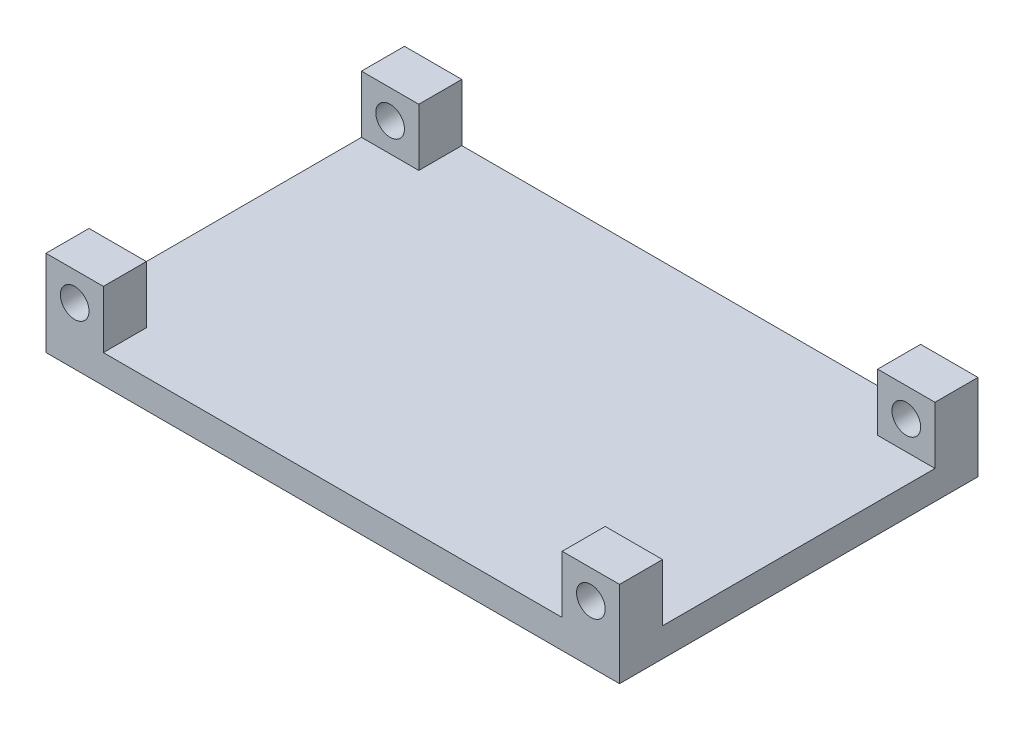
from build123d import *

# Parameters (mm, degrees)
SKETCH1_W           = 400
SKETCH1_H           = 250
BOSS_EXTRUDE1_DEPTH = 20
SKETCH2_W           = 40
SKETCH2_H           = 40
SKETCH2_R           = 10
BOSS_EXTRUDE2_DEPTH = 30


with BuildPart() as part:
    # Sketch1 → Boss-Extrude1 (new body)
    with BuildSketch(Plane(origin=(0, 0, 0), x_dir=(1, 0, 0), z_dir=(0, 1, 0))):
        Rectangle(SKETCH1_W, SKETCH1_H)
    extrude(amount=BOSS_EXTRUDE1_DEPTH)

    # Sketch2 → Boss-Extrude2 (add)
    with BuildSketch(Plane.XY.offset(125)):
        with Locations((-180, 40)):
            Rectangle(SKETCH2_W, SKETCH2_H)
        with Locations((-180, 40)):
            Circle(SKETCH2_R, mode=Mode.SUBTRACT)
        with Locations((180, 40)):
            Rectangle(SKETCH2_W, SKETCH2_H)
        with Locations((180, 40)):
            Circle(SKETCH2_R, mode=Mode.SUBTRACT)
    boss_extrude2 = extrude(amount=-BOSS_EXTRUDE2_DEPTH)

    # Mirror1: Boss-Extrude2 across plane
    add(boss_extrude2.mirror(Plane.XY))


solid = part.part
